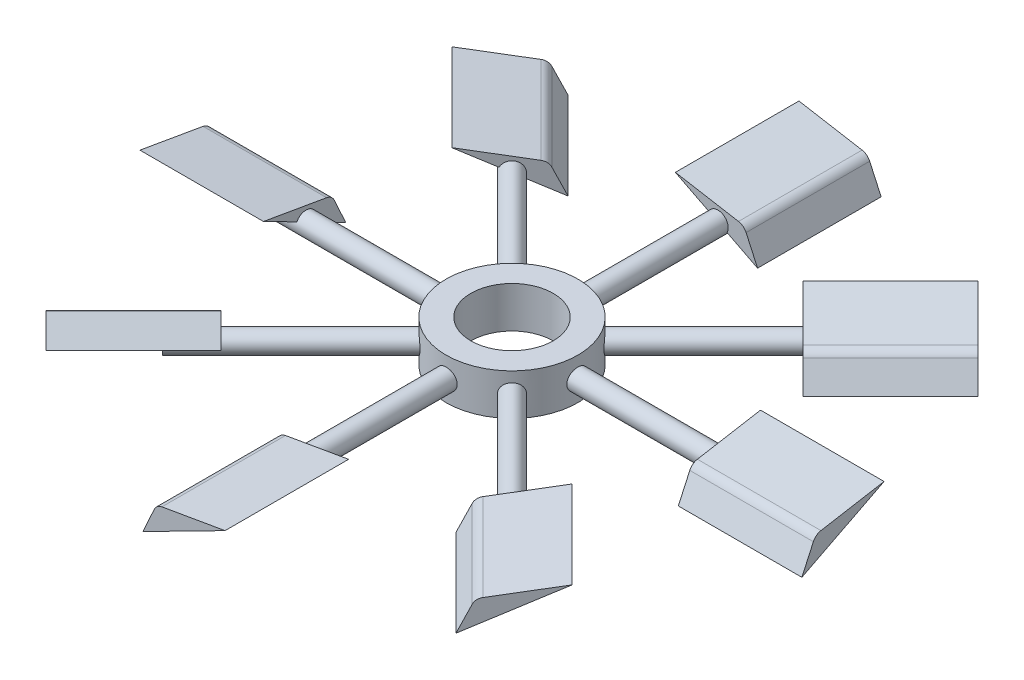
from build123d import *

# Parameters (mm, degrees)
SKETCH1_R           = 20.32
SKETCH1_R_2         = 12.7
BOSS_EXTRUDE1_DEPTH = 12.7
SKETCH2_W           = 3.175
SKETCH2_H           = 56.129579601
BOSS_EXTRUDE2_DEPTH = 38.1
CIRPATTERN1_COUNT   = 8


with BuildPart() as part:
    # Sketch1 → Boss-Extrude1 (new body)
    with BuildSketch(Plane(origin=(0, 0, 0), x_dir=(1, 0, 0), z_dir=(0, 1, 0))):
        Circle(SKETCH1_R)
        Circle(SKETCH1_R_2, mode=Mode.SUBTRACT)
    extrude(amount=BOSS_EXTRUDE1_DEPTH)

    # Sketch2 → Revolve1 (revolve)
    with BuildSketch(Plane(origin=(0, 6.35, 0), x_dir=(1, 0, 0), z_dir=(0, 1, 0))):
        with Locations((1.5875, 48.1352102)):
            Rectangle(SKETCH2_W, SKETCH2_H)
    revolve1 = revolve(axis=Axis((0, 6.35, -20.070420399), (0, 0, -1)))

    # Sketch4 → Boss-Extrude2 (add)
    with BuildSketch(Plane(origin=(0, 0, -63.5), x_dir=(-1, 0, 0), z_dir=(0, 0, -1))):
        with BuildLine():
            Line((-12.221045486, 0.123066306), (13.126308114, 13.038188042))
            Line((13.126308114, 13.038188042), (-6.337477412, 9.661472478))
            ThreePointArc((-6.337477412, 9.661472478), (-7.732958134, 9.047961526), (-8.681650548, 7.854753733))
            Line((-8.681650548, 7.854753733), (-12.221045486, 0.123066306))
        make_face()
    boss_extrude2 = extrude(amount=BOSS_EXTRUDE2_DEPTH)

    # CirPattern1: Revolve1, Boss-Extrude2 ×8 about axis
    cirpattern1_axis = Axis((0, 0, 0), (0, 1, 0))
    for i in range(1, CIRPATTERN1_COUNT):
        add(revolve1.rotate(cirpattern1_axis, i * 360 / CIRPATTERN1_COUNT))
        add(boss_extrude2.rotate(cirpattern1_axis, i * 360 / CIRPATTERN1_COUNT))


solid = part.part
